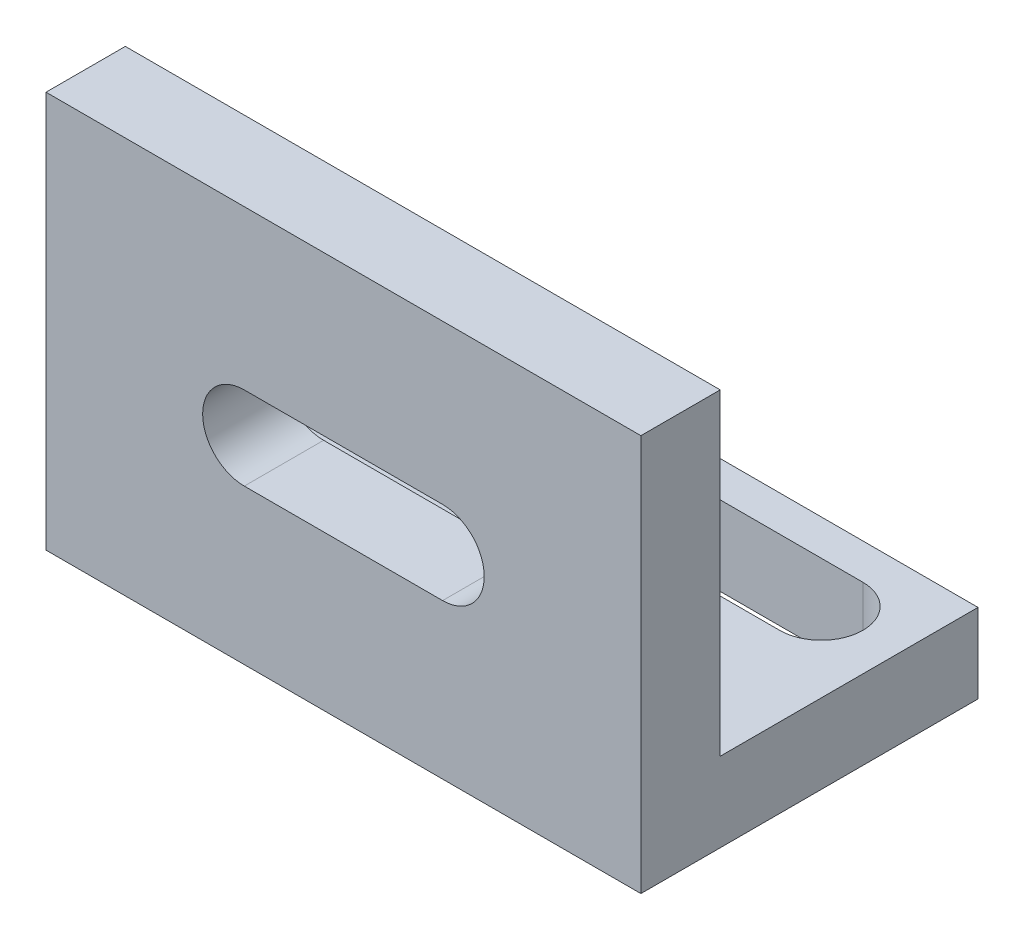
from build123d import *

# Parameters (mm, degrees)
SKETCH1_W           = 30
SKETCH1_H           = 17
BOSS_EXTRUDE1_DEPTH = 4
SKETCH5_W           = 30
SKETCH5_H           = 4
BOSS_EXTRUDE2_DEPTH = 16
CUT_EXTRUDE3_DEPTH  = 10
CUT_EXTRUDE5_DEPTH  = 10


with BuildPart() as part:
    # Sketch1 → Boss-Extrude1 (new body)
    with BuildSketch(Plane(origin=(0, 0, 0), x_dir=(1, 0, 0), z_dir=(0, 1, 0))):
        with Locations((-29.259259259, 2.888888889)):
            Rectangle(SKETCH1_W, SKETCH1_H)
    extrude(amount=BOSS_EXTRUDE1_DEPTH)

    # Sketch5 → Boss-Extrude2 (add)
    with BuildSketch(Plane(origin=(0, 4, 0), x_dir=(1, 0, 0), z_dir=(0, 1, 0))):
        with Locations((-29.259259259, -3.611111111)):
            Rectangle(SKETCH5_W, SKETCH5_H)
    extrude(amount=BOSS_EXTRUDE2_DEPTH)

    # Sketch7 → Cut-Extrude3 (cut)
    with BuildSketch(Plane(origin=(0, 4, 0), x_dir=(1, 0, 0), z_dir=(0, 1, 0))):
        with BuildLine():
            Line((-18.259259259, 5.384968307), (-40.259259259, 5.384968307))
            ThreePointArc((-40.259259259, 5.384968307), (-42.359259259, 7.484968307), (-40.259259259, 9.584968307))
            Line((-40.259259259, 9.584968307), (-18.259259259, 9.584968307))
            ThreePointArc((-18.259259259, 9.584968307), (-16.159259259, 7.484968307), (-18.259259259, 5.384968307))
        make_face()
    extrude(amount=-CUT_EXTRUDE3_DEPTH, mode=Mode.SUBTRACT)

    # Sketch8 → Cut-Extrude5 (cut)
    with BuildSketch(Plane(origin=(0, 0, 1.611111111), x_dir=(-1, 0, 0), z_dir=(0, 0, -1))):
        with BuildLine():
            Line((24.259259259, 11.997218425), (34.259259259, 11.997218425))
            ThreePointArc((34.259259259, 11.997218425), (36.359259259, 9.897218425), (34.259259259, 7.797218425))
            Line((34.259259259, 7.797218425), (24.259259259, 7.797218425))
            ThreePointArc((24.259259259, 7.797218425), (22.159259259, 9.897218425), (24.259259259, 11.997218425))
        make_face()
    extrude(amount=-CUT_EXTRUDE5_DEPTH, mode=Mode.SUBTRACT)


solid = part.part
